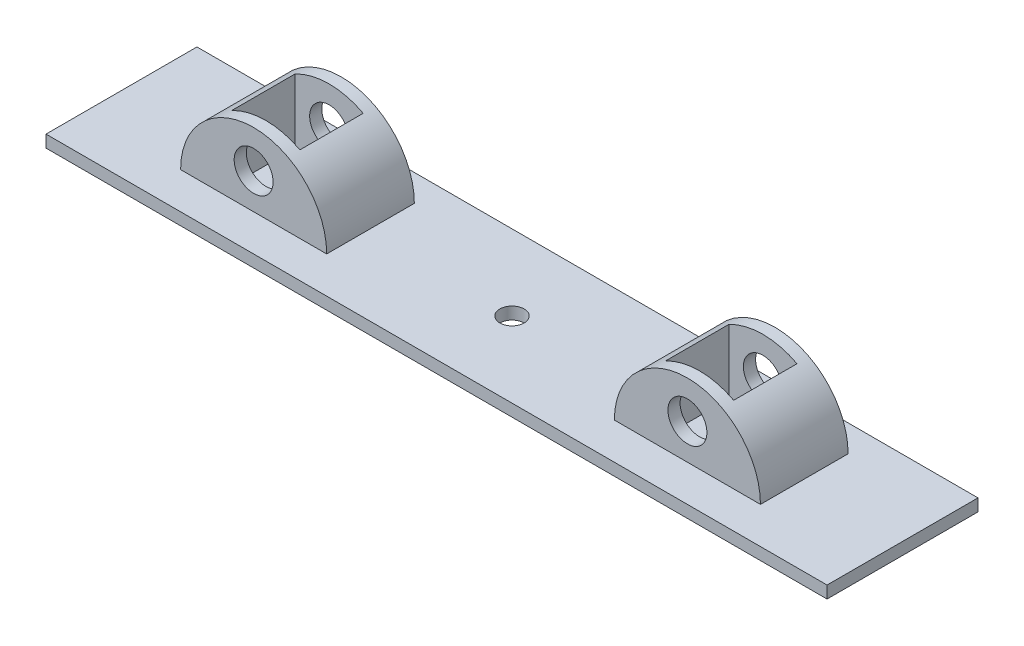
from build123d import *

# Parameters (mm, degrees)
SKETCH1_W           = 160.4
SKETCH1_H           = 31
SKETCH1_R           = 2.5
BOSS_EXTRUDE1_DEPTH = 2.5
BOSS_EXTRUDE2_START = -7.5
SKETCH2_R           = 4
BOSS_EXTRUDE2_DEPTH = 18
SKETCH3_W           = 14
SKETCH3_H           = 13
CUT_EXTRUDE1_DEPTH  = 18


with BuildPart() as part:
    # Sketch1 → Boss-Extrude1 (new body)
    with BuildSketch(Plane(origin=(0, 0, 0), x_dir=(1, 0, 0), z_dir=(0, 1, 0))):
        with Locations((80.2, 15.5)):
            Rectangle(SKETCH1_W, SKETCH1_H)
        with Locations((80.2, 15.5)):
            Circle(SKETCH1_R, mode=Mode.SUBTRACT)
    extrude(amount=BOSS_EXTRUDE1_DEPTH)

    # Sketch2 → Boss-Extrude2 (add)
    with BuildSketch(Plane.XY.offset(BOSS_EXTRUDE2_START)):
        with BuildLine():
            Line((20.142837701, 2.5), (50.142837701, 2.5))
            ThreePointArc((50.142837701, 2.5), (35.142837701, 17.5), (20.142837701, 2.5))
        make_face()
        with Locations((35.142837701, 9.772919339)):
            Circle(SKETCH2_R, mode=Mode.SUBTRACT)
        with BuildLine():
            Line((109.22381187, 2.5), (139.22381187, 2.5))
            ThreePointArc((139.22381187, 2.5), (124.22381187, 17.5), (109.22381187, 2.5))
        make_face()
        with Locations((124.22381187, 9.772919339)):
            Circle(SKETCH2_R, mode=Mode.SUBTRACT)
    extrude(amount=-BOSS_EXTRUDE2_DEPTH)

    # Sketch3 → Cut-Extrude1 (cut)
    with BuildSketch(Plane(origin=(0, 2.5, 0), x_dir=(1, 0, 0), z_dir=(0, 1, 0))):
        with Locations((35.142837701, 16.5)):
            Rectangle(SKETCH3_W, SKETCH3_H)
        with Locations((124.22381187, 16.5)):
            Rectangle(SKETCH3_W, SKETCH3_H)
    extrude(amount=CUT_EXTRUDE1_DEPTH, mode=Mode.SUBTRACT)


solid = part.part
